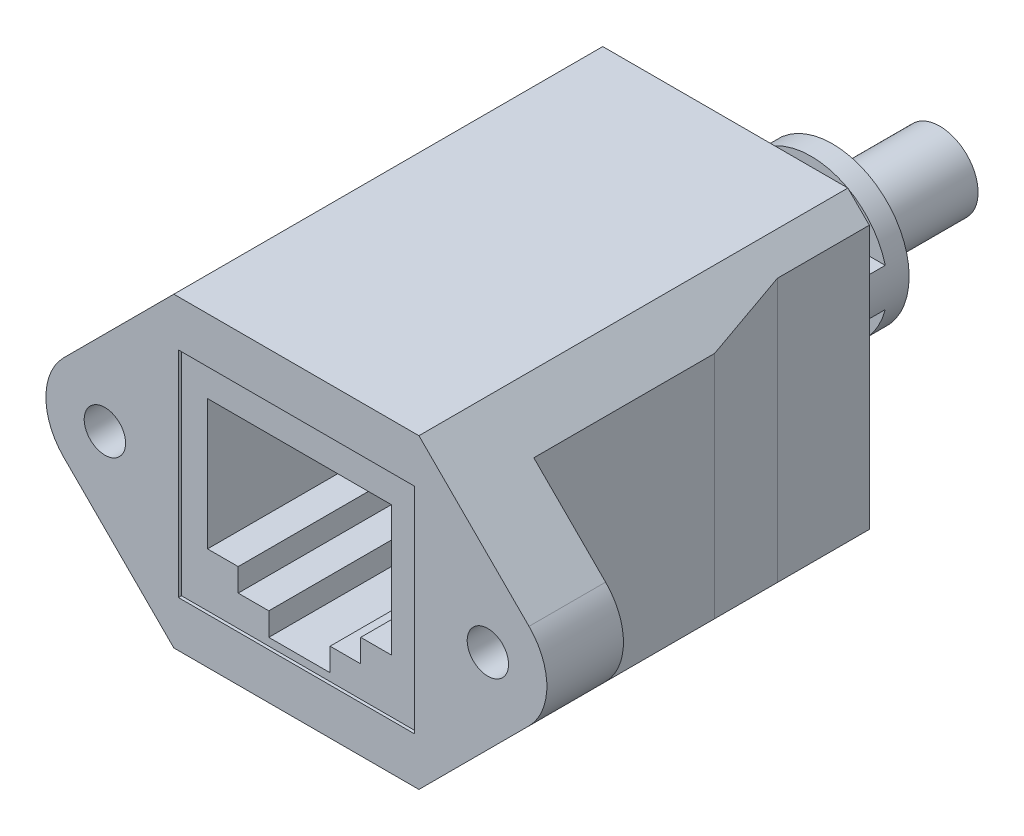
from build123d import *

# Parameters (mm, degrees)
BOSS_EXTRUDE1_DEPTH      = 28
CUT_EXTRUDE1_DEPTH       = 11
CUT_EXTRUDE2_REACH       = 30
SKETCH3_R                = 1.35
FILLET1_R                = 3.98
SKETCH4_R                = 5
BOSS_EXTRUDE2_DEPTH      = 7
SKETCH6_W                = 1.4
SKETCH6_H                = 3.75
CUT_EXTRUDE3_DEPTH       = 17.351430022
SKETCH5_R                = 2.5
BOSS_EXTRUDE3_DEPTH      = 7
BOSS_EXTRUDE3_DEPTH_BACK = 7
SKETCH7_W                = 15.4
SKETCH7_H                = 14
CUT_EXTRUDE4_DEPTH       = 0.2
CUT_EXTRUDE5_DEPTH       = 12


with BuildPart() as part:
    # Sketch1 → Boss-Extrude1 (new body)
    with BuildSketch(Plane.XY):
        Polygon((8, 10), (18, 0), (8, -10), (-8, -10), (-18, 0), (-8, 10), align=None)
    extrude(amount=-BOSS_EXTRUDE1_DEPTH)

    # Sketch2 → Cut-Extrude1 (cut, symmetric)
    with BuildSketch(Plane(origin=(0, 0, 0), x_dir=(1, 0, 0), z_dir=(0, 1, 0))):
        Polygon((-18, 5), (-10.5, 5), (-10.5, 16.8), (-9.4, 22), (-9.4, 28), (-18, 28), align=None)
    cut_extrude1 = extrude(amount=CUT_EXTRUDE1_DEPTH, both=True, mode=Mode.SUBTRACT)

    # Mirror1: Cut-Extrude1 across plane
    add(cut_extrude1.mirror(Plane(origin=(0, 0, 0), x_dir=(0, 0, 1), z_dir=(1, 0, 0))), mode=Mode.SUBTRACT)

    # Sketch3 → Cut-Extrude2 (cut, up to next)
    with BuildSketch(Plane.XY, mode=Mode.PRIVATE) as cut_extrude2_sk1:
        with Locations((-12.5, 0)):
            Circle(SKETCH3_R)
    cut_extrude2_tool1 = extrude(cut_extrude2_sk1.sketch, amount=-CUT_EXTRUDE2_REACH, mode=Mode.PRIVATE) & part.part
    add(cut_extrude2_tool1.solids().sort_by_distance((-12.5, 0, 0))[0], mode=Mode.SUBTRACT)
    # Sketch3 → Cut-Extrude2 (cut, up to next)
    with BuildSketch(Plane.XY, mode=Mode.PRIVATE) as cut_extrude2_sk2:
        with Locations((12.5, 0)):
            Circle(SKETCH3_R)
    cut_extrude2_tool2 = extrude(cut_extrude2_sk2.sketch, amount=-CUT_EXTRUDE2_REACH, mode=Mode.PRIVATE) & part.part
    add(cut_extrude2_tool2.solids().sort_by_distance((12.5, 0, 0))[0], mode=Mode.SUBTRACT)

    # Fillet1
    fillet1_edges = [part.edges().sort_by_distance(p)[0] for p in [
        (-18, 0, -2.5),
        (18, 0, -2.5),
    ]]
    fillet(fillet1_edges, radius=FILLET1_R)

    # Sketch4 → Boss-Extrude2 (add)
    with BuildSketch(Plane(origin=(0, 0, -28), x_dir=(-1, 0, 0), z_dir=(0, 0, -1))):
        Circle(SKETCH4_R)
    extrude(amount=BOSS_EXTRUDE2_DEPTH)

    # Sketch6 → Cut-Extrude3 (cut, symmetric)
    with BuildSketch(Plane(origin=(0, 0, 0), x_dir=(0, 0, -1), z_dir=(1, 0, 0))):
        with Locations((30.1, 3.125)):
            Rectangle(SKETCH6_W, SKETCH6_H)
        with Locations((32.9, 3.125)):
            Rectangle(SKETCH6_W, SKETCH6_H)
    cut_extrude3 = extrude(amount=CUT_EXTRUDE3_DEPTH, both=True, mode=Mode.SUBTRACT)

    # Mirror2: Cut-Extrude3 across plane
    add(cut_extrude3.mirror(Plane.ZX), mode=Mode.SUBTRACT)

    # Sketch5 → Boss-Extrude3 (add, two sides)
    with BuildSketch(Plane(origin=(0, 0, -35), x_dir=(-1, 0, 0), z_dir=(0, 0, -1))) as boss_extrude3_sk:
        Circle(SKETCH5_R)
    extrude(amount=BOSS_EXTRUDE3_DEPTH)
    extrude(boss_extrude3_sk.sketch, amount=-BOSS_EXTRUDE3_DEPTH_BACK)

    # Sketch7 → Cut-Extrude4 (cut)
    with BuildSketch(Plane.XY):
        Rectangle(SKETCH7_W, SKETCH7_H)
    extrude(amount=-CUT_EXTRUDE4_DEPTH, mode=Mode.SUBTRACT)

    # Sketch8 → Cut-Extrude5 (cut)
    with BuildSketch(Plane.XY.offset(-0.2)):
        Polygon((-6, 5), (6, 5), (6, -3.5), (4, -3.5), (4, -5), (2, -5), (2, -6.5), (-2, -6.5), (-2, -5), (-4, -5), (-4, -3.5), (-6, -3.5), align=None)
    extrude(amount=-CUT_EXTRUDE5_DEPTH, mode=Mode.SUBTRACT)


solid = part.part
